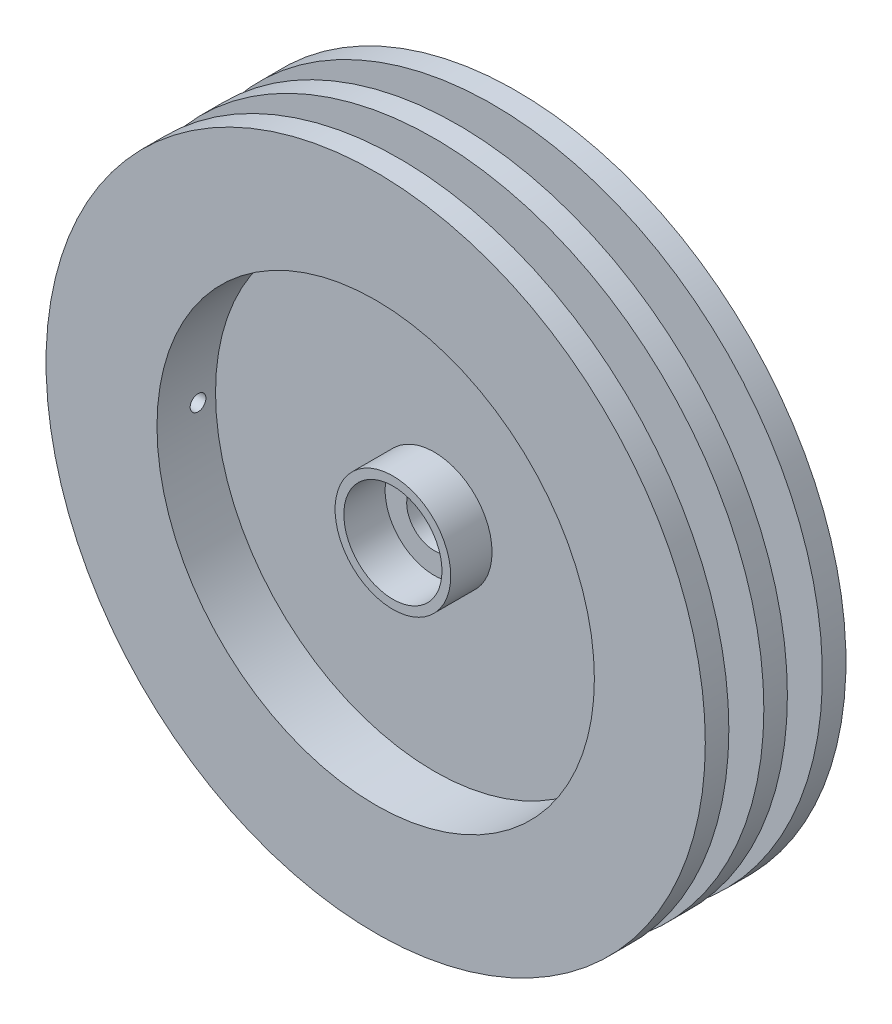
from build123d import *

# Parameters (mm, degrees)
SKETCH1_R               = 23.9268
BOSS_EXTRUDE1_DEPTH     = 1.70942
SKETCH2_R               = 19.0119
BOSS_EXTRUDE2_DEPTH     = 2.54
SKETCH3_R               = 19.0119
BOSS_EXTRUDE3_DEPTH     = 2.54
SKETCH4_R               = 23.9268
BOSS_EXTRUDE4_DEPTH     = 1.70942
SKETCH5_R               = 23.9268
BOSS_EXTRUDE5_DEPTH     = 1.70942
SKETCH6_R               = 15.875
CUT_EXTRUDE1_DEPTH      = 4.24942
SKETCH7_R               = 15.875
CUT_EXTRUDE2_DEPTH      = 4.24942
SKETCH8_R               = 0.5715
CUT_EXTRUDE3_DEPTH      = 24.9268
CUT_EXTRUDE3_DEPTH_BACK = 24.9268
CUT_EXTRUDE4_DEPTH      = 6.9588401
SKETCH10_R              = 4.1975
SKETCH10_R_2            = 3.5625
BOSS_EXTRUDE7_DEPTH     = 3
SKETCH11_R              = 4.1975
SKETCH11_R_2            = 3.5625
BOSS_EXTRUDE8_DEPTH     = 3


with BuildPart() as part:
    # Sketch1 → Boss-Extrude1 (new body)
    with BuildSketch(Plane.XY):
        Circle(SKETCH1_R)
    extrude(amount=BOSS_EXTRUDE1_DEPTH)

    # Sketch2 → Boss-Extrude2 (add)
    with BuildSketch(Plane.XY.offset(1.70942)):
        Circle(SKETCH2_R)
    extrude(amount=BOSS_EXTRUDE2_DEPTH)

    # Sketch3 → Boss-Extrude3 (add)
    with BuildSketch(Plane(origin=(0, 0, 0), x_dir=(-1, 0, 0), z_dir=(0, 0, -1))):
        Circle(SKETCH3_R)
    extrude(amount=BOSS_EXTRUDE3_DEPTH)

    # Sketch4 → Boss-Extrude4 (add)
    with BuildSketch(Plane.XY.offset(4.24942)):
        Circle(SKETCH4_R)
    extrude(amount=BOSS_EXTRUDE4_DEPTH)

    # Sketch5 → Boss-Extrude5 (add)
    with BuildSketch(Plane(origin=(0, 0, -2.54), x_dir=(-1, 0, 0), z_dir=(0, 0, -1))):
        Circle(SKETCH5_R)
    extrude(amount=BOSS_EXTRUDE5_DEPTH)

    # Sketch6 → Cut-Extrude1 (cut)
    with BuildSketch(Plane.XY.offset(5.95884)):
        Circle(SKETCH6_R)
    extrude(amount=-CUT_EXTRUDE1_DEPTH, mode=Mode.SUBTRACT)

    # Sketch7 → Cut-Extrude2 (cut)
    with BuildSketch(Plane(origin=(0, 0, -4.24942), x_dir=(-1, 0, 0), z_dir=(0, 0, -1))):
        Circle(SKETCH7_R)
    extrude(amount=-CUT_EXTRUDE2_DEPTH, mode=Mode.SUBTRACT)

    # Sketch8 → Cut-Extrude3 (cut, two sides)
    with BuildSketch(Plane(origin=(0, 0, 0), x_dir=(0, 0, -1), z_dir=(1, 0, 0))) as cut_extrude3_sk:
        with Locations((-2.97942, 0)):
            Circle(SKETCH8_R)
        with Locations((1.27, 0)):
            Circle(SKETCH8_R)
    extrude(amount=CUT_EXTRUDE3_DEPTH, mode=Mode.SUBTRACT)
    extrude(cut_extrude3_sk.sketch, amount=-CUT_EXTRUDE3_DEPTH_BACK, mode=Mode.SUBTRACT)

    # Sketch9 → Cut-Extrude4 (cut, through all)
    with BuildSketch(Plane.XY.offset(1.70942)):
        with BuildLine():
            Line((-1.322875656, 1.5), (1.322875656, 1.5))
            ThreePointArc((1.322875656, 1.5), (0, -2), (-1.322875656, 1.5))
        make_face()
    extrude(amount=-CUT_EXTRUDE4_DEPTH, mode=Mode.SUBTRACT)

    # Sketch10 → Boss-Extrude7 (add)
    with BuildSketch(Plane.XY.offset(1.70942)):
        Circle(SKETCH10_R)
        Circle(SKETCH10_R_2, mode=Mode.SUBTRACT)
    extrude(amount=BOSS_EXTRUDE7_DEPTH)

    # Sketch11 → Boss-Extrude8 (add)
    with BuildSketch(Plane(origin=(0, 0, 0), x_dir=(-1, 0, 0), z_dir=(0, 0, -1))):
        Circle(SKETCH11_R)
        Circle(SKETCH11_R_2, mode=Mode.SUBTRACT)
    extrude(amount=BOSS_EXTRUDE8_DEPTH)


solid = part.part
